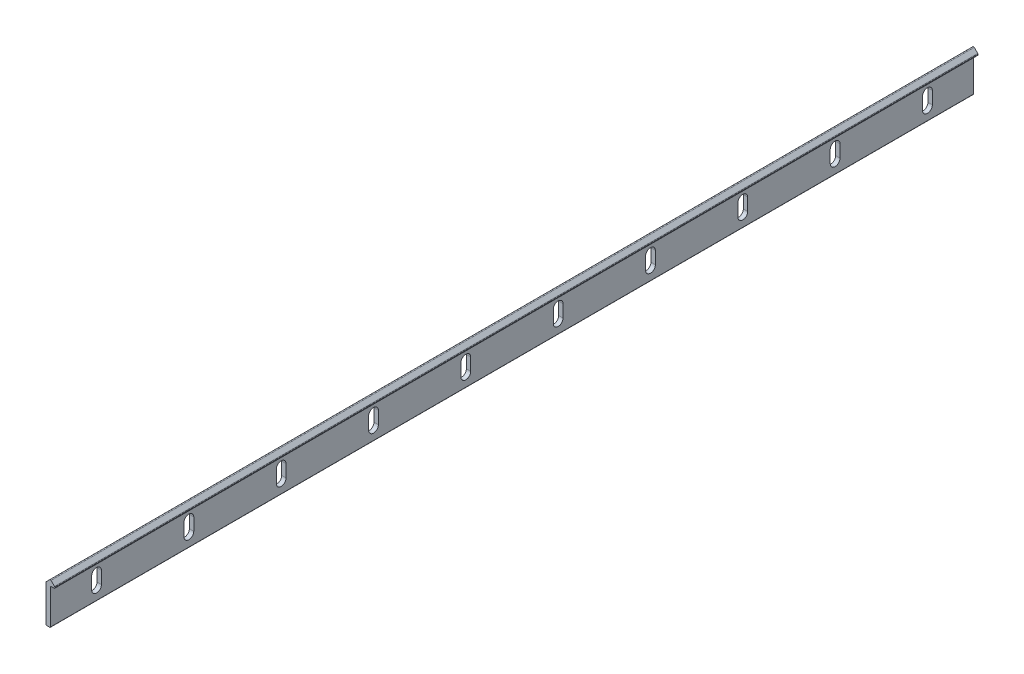
from build123d import *

# Parameters (mm, degrees)
BOSS_EXTRUDE1_DEPTH = 500
FILLET1_R           = 0.50329666
FILLET2_R           = 0.50398302
FILLET3_R           = 0.30157619
FILLET4_R           = 0.30157551
CUT_EXTRUDE1_DEPTH  = 2.375
LPATTERN1_COUNT     = 10
LPATTERN1_PITCH     = 50


with BuildPart() as part:
    # Sketch1 → Boss-Extrude1 (new body)
    with BuildSketch(Plane.XY):
        with BuildLine():
            Line((0, 20.330194912), (2.019589054, 22.349783966))
            ThreePointArc((2.019589054, 22.349783966), (2.375, 22.497), (2.730410946, 22.349783966))
            Line((2.730410946, 22.349783966), (4.75, 20.330194912))
            Line((4.75, 20.330194912), (4.75, 19.5291))
            Line((4.75, 19.5291), (2.375, 19.5291))
            Line((2.375, 19.5291), (2.375, 0))
            Line((2.375, 0), (0, 0))
            Line((0, 0), (0, 20.330194912))
        make_face()
    extrude(amount=BOSS_EXTRUDE1_DEPTH)

    # Fillet1
    fillet1_edges = [part.edges().sort_by_distance(p)[0] for p in [
        (0, 20.330194912, 250),
    ]]
    fillet(fillet1_edges, radius=FILLET1_R)

    # Fillet2
    fillet2_edges = [part.edges().sort_by_distance(p)[0] for p in [
        (4.75, 20.330194912, 250),
    ]]
    fillet(fillet2_edges, radius=FILLET2_R)

    # Fillet3
    fillet3_edges = [part.edges().sort_by_distance(p)[0] for p in [
        (4.75, 19.5291, 250),
    ]]
    fillet(fillet3_edges, radius=FILLET3_R)

    # Fillet4
    fillet4_edges = [part.edges().sort_by_distance(p)[0] for p in [
        (2.375, 0, 250),
        (0, 0, 250),
    ]]
    fillet(fillet4_edges, radius=FILLET4_R)

    # Sketch2 → Cut-Extrude1 (cut)
    with BuildSketch(Plane.ZY):
        with BuildLine():
            Line((27.65, 13.1043), (27.65, 6.4043))
            ThreePointArc((27.65, 6.4043), (25, 3.7543), (22.35, 6.4043))
            Line((22.35, 6.4043), (22.35, 13.1043))
            ThreePointArc((22.35, 13.1043), (25, 15.7543), (27.65, 13.1043))
        make_face()
    cut_extrude1 = extrude(amount=-CUT_EXTRUDE1_DEPTH, mode=Mode.SUBTRACT)

    # LPattern1: Cut-Extrude1 ×10
    with Locations(*[(0, 0, i * LPATTERN1_PITCH) for i in range(1, LPATTERN1_COUNT)]):
        add(cut_extrude1, mode=Mode.SUBTRACT)


solid = part.part
